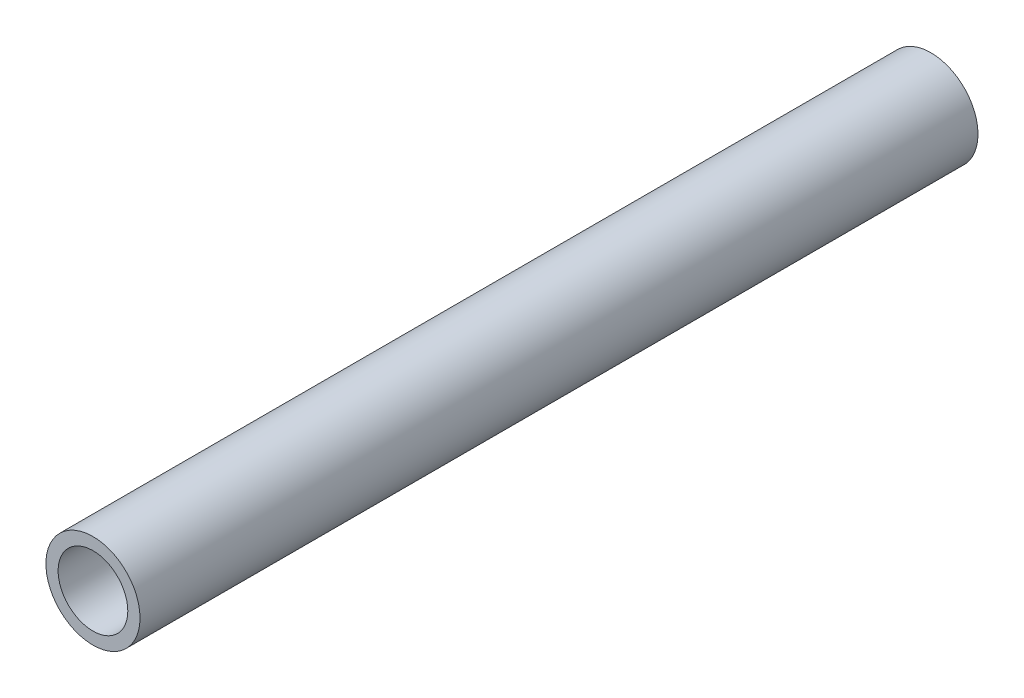
from build123d import *

# Parameters (mm, degrees)
SKETCH1_R           = 10.668
SKETCH1_R_2         = 7.8994
EXTRUDE_THIN1_DEPTH = 95


with BuildPart() as part:
    # Sketch1 → Extrude-Thin1 (new body, symmetric)
    with BuildSketch(Plane.XY):
        Circle(SKETCH1_R)
        Circle(SKETCH1_R_2, mode=Mode.SUBTRACT)
    extrude(amount=EXTRUDE_THIN1_DEPTH, both=True)


solid = part.part
